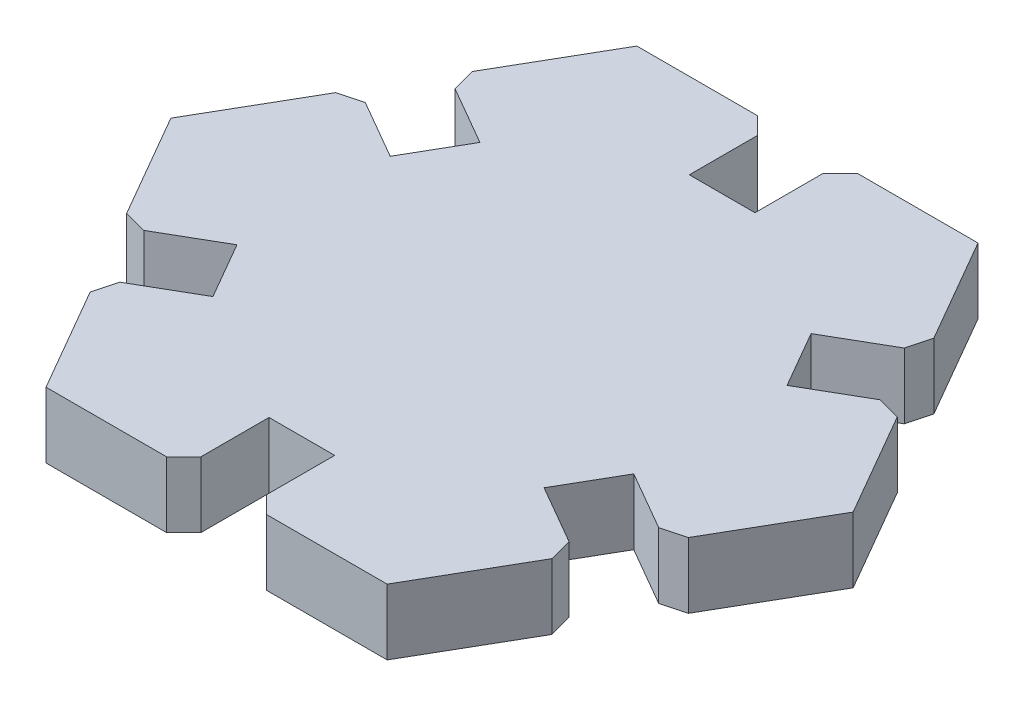
from build123d import *

# Parameters (mm, degrees)
BOSS_EXTRUDE1_DEPTH = 3.85
CHAMFER1_SIZE       = 1


with BuildPart() as part:
    # Sketch1 → Boss-Extrude1 (new body)
    with BuildSketch(Plane(origin=(0, 0, 0), x_dir=(1, 0, 0), z_dir=(0, 1, 0))):
        Polygon((20, 0), (15.9625, 6.993155136), (11.632372981, 4.493155136), (9.707372981, 7.82735294), (14.0375, 10.32735294), (10, 17.320508076), (1.925, 17.320508076), (1.925, 12.320508076), (-1.925, 12.320508076), (-1.925, 17.320508076), (-10, 17.320508076), (-14.0375, 10.32735294), (-9.707372981, 7.82735294), (-11.632372981, 4.493155136), (-15.9625, 6.993155136), (-20, 0), (-15.9625, -6.993155136), (-11.632372981, -4.493155136), (-9.707372981, -7.82735294), (-14.0375, -10.32735294), (-10, -17.320508076), (-1.925, -17.320508076), (-1.925, -12.320508076), (1.925, -12.320508076), (1.925, -17.320508076), (10, -17.320508076), (14.0375, -10.32735294), (9.707372981, -7.82735294), (11.632372981, -4.493155136), (15.9625, -6.993155136), align=None)
    extrude(amount=BOSS_EXTRUDE1_DEPTH)

    # Chamfer1
    chamfer1_edges = [part.edges().sort_by_distance(p)[0] for p in [
        (15.9625, 1.925, 6.993155136),
        (15.9625, 1.925, -6.993155136),
        (14.0375, 1.925, -10.32735294),
        (1.925, 1.925, -17.320508076),
        (-1.925, 1.925, -17.320508076),
        (-14.0375, 1.925, -10.32735294),
        (-15.9625, 1.925, -6.993155136),
        (-15.9625, 1.925, 6.993155136),
        (-14.0375, 1.925, 10.32735294),
        (-1.925, 1.925, 17.320508076),
        (1.925, 1.925, 17.320508076),
        (14.0375, 1.925, 10.32735294),
    ]]
    chamfer(chamfer1_edges, length=CHAMFER1_SIZE)


solid = part.part
